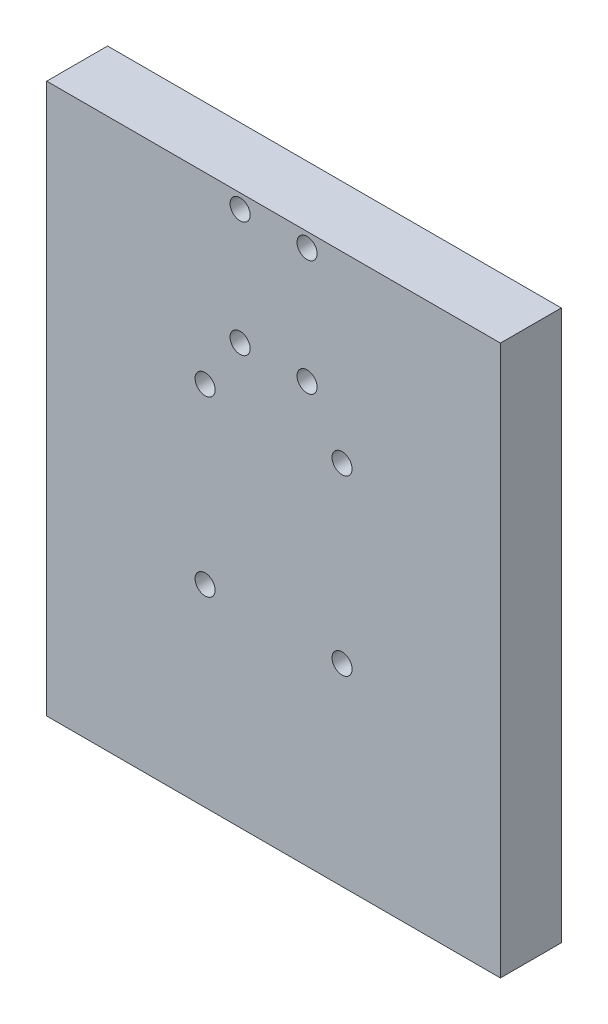
from build123d import *

# Parameters (mm, degrees)
SKETCH1_W                = 149.100450595
SKETCH1_H                = 180.7
BOSS_EXTRUDE1_DEPTH      = 20
M6_CLEARANCE_HOLE1_D     = 6.6
M6_CLEARANCE_HOLE1_DEPTH = 36.6
M6_CLEARANCE_HOLE1_TIP   = 1.982840043


with BuildPart() as part:
    # Sketch1 → Boss-Extrude1 (new body)
    with BuildSketch(Plane.XY):
        with Locations((-126.988568818, 2276.898566852)):
            Rectangle(SKETCH1_W, SKETCH1_H)
    extrude(amount=BOSS_EXTRUDE1_DEPTH)

    # M6 Clearance Hole1
    with Locations(Plane.XY.offset(20)):
        with Locations((-149.488568817, 2307.048566852), (-104.488568817, 2307.048566852), (-104.488568817, 2250.048566852), (-149.488568817, 2250.048566852), (-137.988568818, 2362.548566852), (-137.988568818, 2324.548566852), (-115.988568818, 2324.548566852), (-115.988568818, 2362.548566852)):
            Hole(M6_CLEARANCE_HOLE1_D / 2, depth=M6_CLEARANCE_HOLE1_DEPTH)
            with Locations((0, 0, -(M6_CLEARANCE_HOLE1_DEPTH + M6_CLEARANCE_HOLE1_TIP / 2))):  # 118° drill point
                Cone(0, M6_CLEARANCE_HOLE1_D / 2, M6_CLEARANCE_HOLE1_TIP, mode=Mode.SUBTRACT)


solid = part.part
